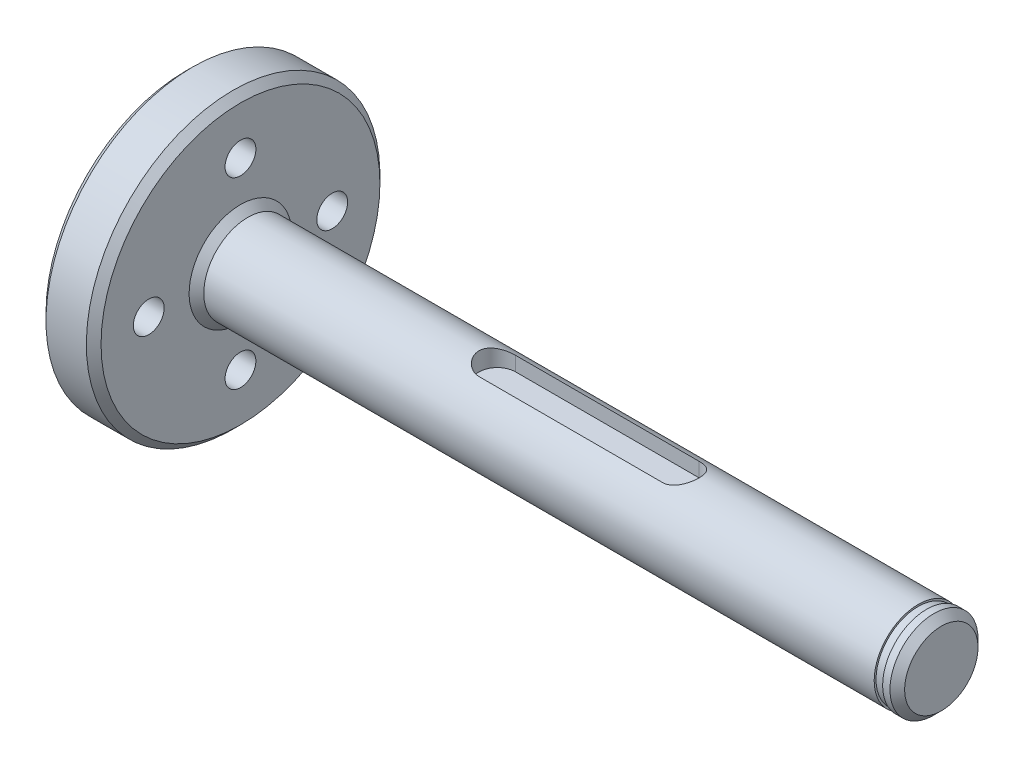
from build123d import *

# Parameters (mm, degrees)
CHAMFER1_SIZE      = 1
M5_TAPPED_HOLE1_D  = 4.2
CUT_EXTRUDE1_DEPTH = 2.5
SKETCH6_W          = 1.15
SKETCH6_H          = 0.25


with BuildPart() as part:
    # Sketch1 → Revolve1 (revolve)
    with BuildSketch(Plane.XY):
        Polygon((0, 0), (0, 20), (7.5, 20), (7.5, 6), (103, 6), (103, 0), align=None)
    revolve(axis=Axis((103, 0, 0), (-1, 0, 0)))

    # Chamfer1
    chamfer1_edges = [part.edges().sort_by_distance(p)[0] for p in [
        (103, -6, 0),
        (7.5, -6, 0),
        (7.5, -20, 0),
        (0, -20, 0),
    ]]
    chamfer(chamfer1_edges, length=CHAMFER1_SIZE)

    # M5 Tapped Hole1 (through all)
    with Locations(Plane.ZY):
        with Locations((-12.5, 0), (0, 12.5), (12.5, 0), (0, -12.5)):
            Hole(M5_TAPPED_HOLE1_D / 2)

    # Sketch5 → Cut-Extrude1 (cut)
    with BuildSketch(Plane(origin=(0, 6, 0), x_dir=(1, 0, 0), z_dir=(0, 1, 0))):
        with BuildLine():
            Line((42.5, 2.5), (67.5, 2.5))
            ThreePointArc((67.5, 2.5), (70, 0), (67.5, -2.5))
            Line((67.5, -2.5), (42.5, -2.5))
            ThreePointArc((42.5, -2.5), (40, 0), (42.5, 2.5))
        make_face()
    extrude(amount=-CUT_EXTRUDE1_DEPTH, mode=Mode.SUBTRACT)

    # Sketch6 → Cut-Revolve1 (revolve, cut)
    with BuildSketch(Plane(origin=(0, 0, 0), x_dir=(1, 0, 0), z_dir=(0, 1, 0))):
        with Locations((100.425, 5.875)):
            Rectangle(SKETCH6_W, SKETCH6_H)
    revolve(axis=Axis((0, 0, 0), (1, 0, 0)), mode=Mode.SUBTRACT)


solid = part.part
